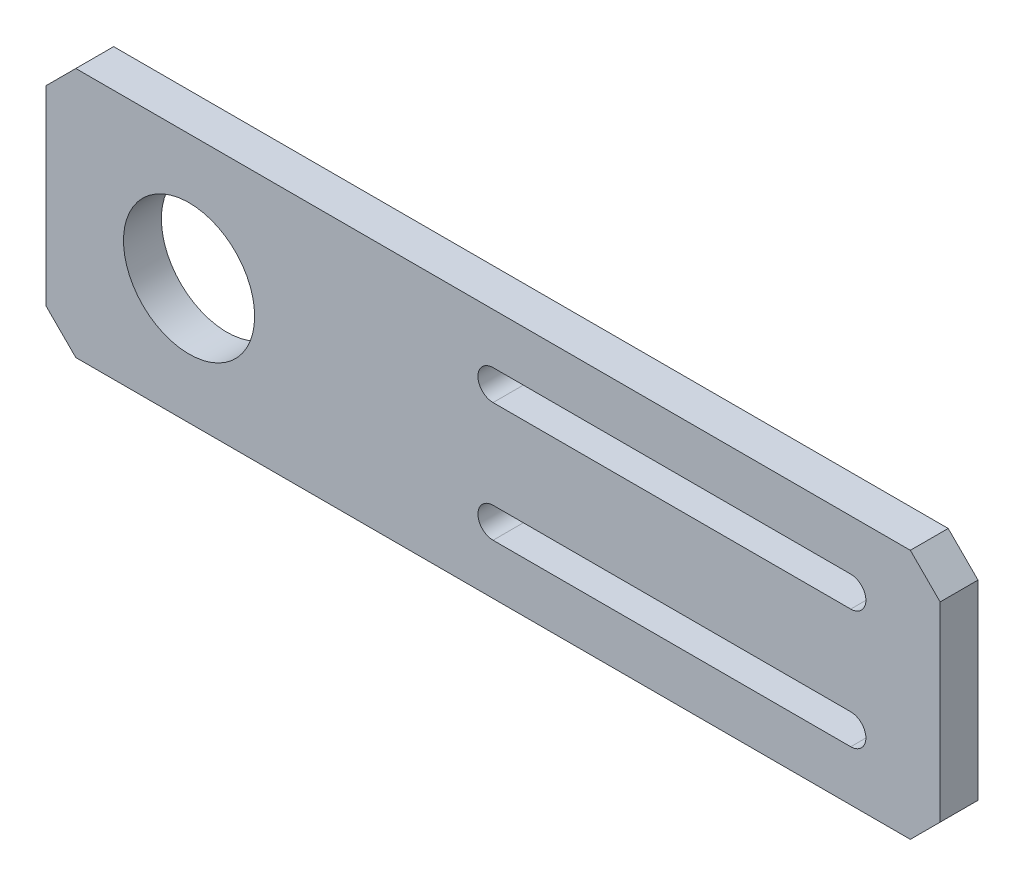
from build123d import *

# Parameters (mm, degrees)
SKETCH1_W           = 205
SKETCH1_H           = 42
BOSS_EXTRUDE1_DEPTH = 6.35
SKETCH4_R           = 11
CUT_EXTRUDE3_DEPTH  = 7.35
CHAMFER1_SIZE       = 5
SKETCH9_R           = 11
CUT_EXTRUDE8_DEPTH  = 7.35
SKETCH13_R          = 11
CUT_EXTRUDE10_DEPTH = 10


with BuildPart() as part:
    # Sketch1 → Boss-Extrude1 (new body)
    with BuildSketch(Plane.XY):
        Rectangle(SKETCH1_W, SKETCH1_H)
    extrude(amount=BOSS_EXTRUDE1_DEPTH)

    # Sketch4 → Cut-Extrude3 (cut, through all)
    with BuildSketch(Plane.XY.offset(6.35)):
        with Locations((-78.5, 0)):
            Circle(SKETCH4_R)
    extrude(amount=-CUT_EXTRUDE3_DEPTH, mode=Mode.SUBTRACT)

    # Chamfer1
    chamfer1_edges = [part.edges().sort_by_distance(p)[0] for p in [
        (102.5, -21, 3.175),
        (-102.5, -21, 3.175),
        (-102.5, 21, 3.175),
        (102.5, 21, 3.175),
    ]]
    chamfer(chamfer1_edges, length=CHAMFER1_SIZE)

    # Sketch9 → Cut-Extrude8 (cut, through all)
    with BuildSketch(Plane.XY.offset(6.35)):
        with Locations((82.5, 0)):
            Circle(SKETCH9_R)
    extrude(amount=-CUT_EXTRUDE8_DEPTH, mode=Mode.SUBTRACT)

    # Sketch13 → Cut-Extrude10 (cut)
    with BuildSketch(Plane.XY.offset(6.35)):
        Polygon((42.5, 21), (47.5, 16), (47.5, -16), (42.5, -21), (97.5, -21), (102.5, -16), (102.5, 16), (97.5, 21), align=None)
        with Locations((82.5, 0)):
            Circle(SKETCH13_R, mode=Mode.SUBTRACT)
        with BuildLine():
            Line((-27.5, 7.46), (32.5, 7.46))
            ThreePointArc((32.5, 7.46), (35.04, 10), (32.5, 12.54))
            Line((32.5, 12.54), (-27.5, 12.54))
            ThreePointArc((-27.5, 12.54), (-30.04, 10), (-27.5, 7.46))
        make_face()
        with BuildLine():
            ThreePointArc((32.5, -7.46), (35.04, -10), (32.5, -12.54))
            Line((32.5, -12.54), (-27.5, -12.54))
            ThreePointArc((-27.5, -12.54), (-30.04, -10), (-27.5, -7.46))
            Line((-27.5, -7.46), (32.5, -7.46))
        make_face()
    extrude(amount=-CUT_EXTRUDE10_DEPTH, mode=Mode.SUBTRACT)


solid = part.part
